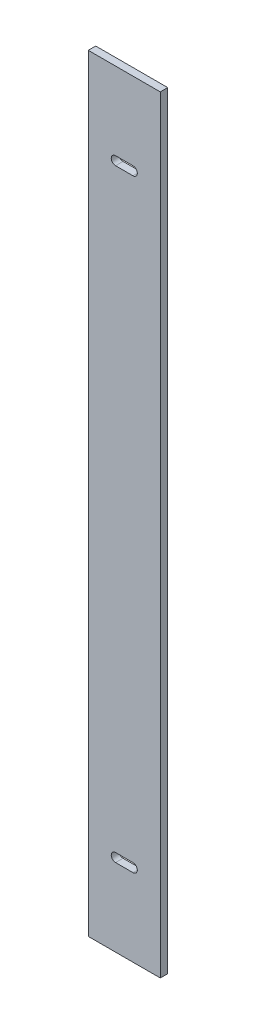
from build123d import *

# Parameters (mm, degrees)
ESQUISSE1_W        = 29
ESQUISSE1_H        = 309
BOSS_EXTRU_1_DEPTH = 3


with BuildPart() as part:
    # Esquisse1 → Boss.-Extru.1 (new body)
    with BuildSketch(Plane.XY):
        Rectangle(ESQUISSE1_W, ESQUISSE1_H)
        with BuildLine():
            Line((-3.5, 123.25), (3.5, 123.25))
            ThreePointArc((3.5, 123.25), (5.25, 121.5), (3.5, 119.75))
            Line((3.5, 119.75), (-3.5, 119.75))
            ThreePointArc((-3.5, 119.75), (-5.25, 121.5), (-3.5, 123.25))
        make_face(mode=Mode.SUBTRACT)
        with BuildLine():
            Line((-3.5, -123.25), (3.5, -123.25))
            ThreePointArc((3.5, -123.25), (5.25, -121.5), (3.5, -119.75))
            Line((3.5, -119.75), (-3.5, -119.75))
            ThreePointArc((-3.5, -119.75), (-5.25, -121.5), (-3.5, -123.25))
        make_face(mode=Mode.SUBTRACT)
    extrude(amount=BOSS_EXTRU_1_DEPTH)


solid = part.part
